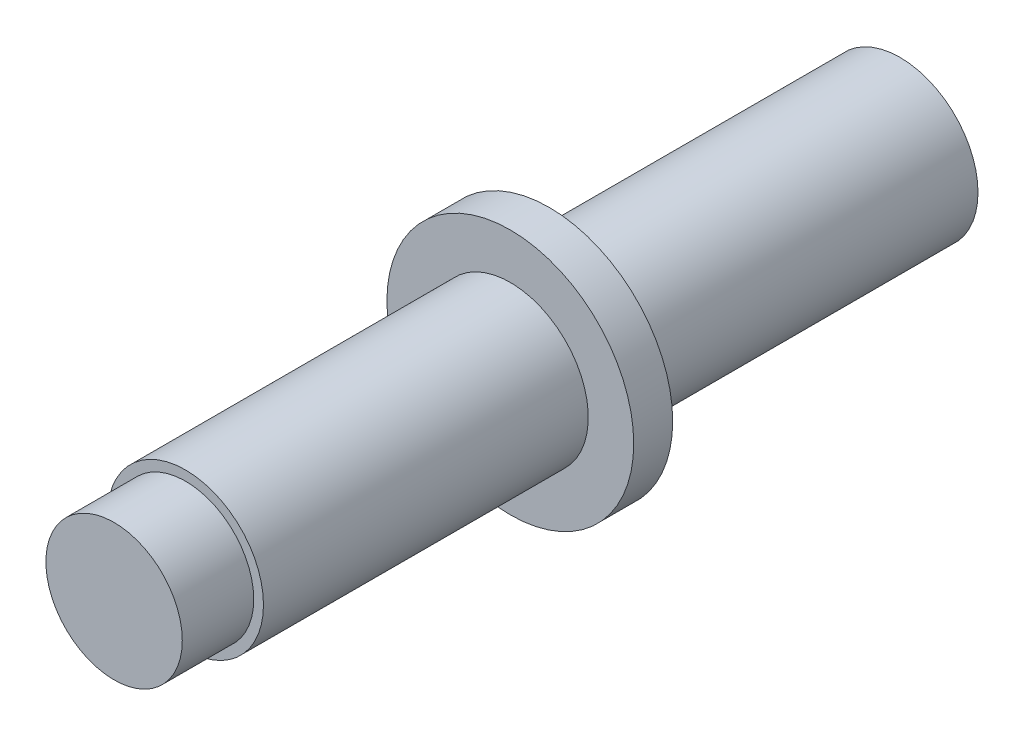
from build123d import *

# Parameters (mm, degrees)
SKETCH_1_R      = 6
EXTRUDE_1_DEPTH = 55
SKETCH_2_R      = 5.25
EXTRUDE_2_DEPTH = 5.5
EXTRUDE_START   = -30
SKETCH_3_R      = 9.5
EXTRUDE_3_DEPTH = 3


with BuildPart() as part:
    # Эскиз1 → Бобышка-Вытянуть1 (new body)
    with BuildSketch(Plane.XY):
        Circle(SKETCH_1_R)
    extrude(amount=EXTRUDE_1_DEPTH)

    # Эскиз2 → Бобышка-Вытянуть2 (add)
    with BuildSketch(Plane.XY.offset(55)):
        Circle(SKETCH_2_R)
    extrude(amount=EXTRUDE_2_DEPTH)

    # Эскиз3 → Бобышка-Вытянуть3 (add)
    with BuildSketch(Plane(origin=(0, 0, 0), x_dir=(-1, 0, 0), z_dir=(0, 0, -1)).offset(EXTRUDE_START)):
        Circle(SKETCH_3_R)
    extrude(amount=EXTRUDE_3_DEPTH)


solid = part.part
